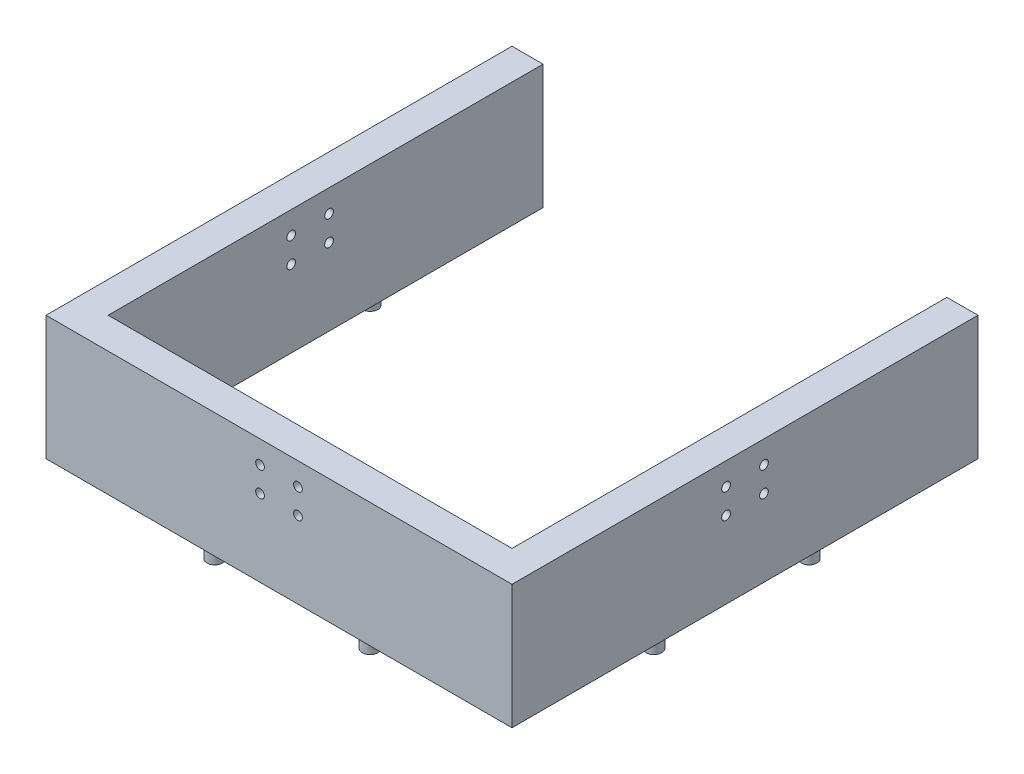
from build123d import *

# Parameters (mm, degrees)
SKETCH1_W           = 150
SKETCH1_H           = 150
BOSS_EXTRUDE1_DEPTH = 40
SKETCH2_W           = 130
SKETCH2_H           = 130
CUT_EXTRUDE1_DEPTH  = 54
SKETCH6_R           = 2.5
BOSS_EXTRUDE5_DEPTH = 5
SKETCH9_R           = 1.4
CUT_EXTRUDE4_DEPTH  = 10
CIRPATTERN1_COUNT   = 3
CIRPATTERN1_ANGLE   = 180
SKETCH10_W          = 130
SKETCH10_H          = 96.398295943
CUT_EXTRUDE6_DEPTH  = 116.217186218


with BuildPart() as part:
    # Sketch1 → Boss-Extrude1 (new body)
    with BuildSketch(Plane(origin=(0, 0, 0), x_dir=(1, 0, 0), z_dir=(0, 1, 0))):
        Rectangle(SKETCH1_W, SKETCH1_H)
    extrude(amount=-BOSS_EXTRUDE1_DEPTH)

    # Sketch2 → Cut-Extrude1 (cut)
    with BuildSketch(Plane(origin=(0, 0, 0), x_dir=(1, 0, 0), z_dir=(0, 1, 0))):
        Rectangle(SKETCH2_W, SKETCH2_H)
    extrude(amount=-CUT_EXTRUDE1_DEPTH, mode=Mode.SUBTRACT)

    # Sketch6 → Boss-Extrude5 (add)
    with BuildSketch(Plane.XZ.offset(40)):
        with Locations((-70.678187872, -25)):
            Circle(SKETCH6_R)
        with Locations((-70.678187872, 25)):
            Circle(SKETCH6_R)
        with Locations((25, 70.678187872)):
            Circle(SKETCH6_R)
        with Locations((-25, 70.678187872)):
            Circle(SKETCH6_R)
        with Locations((70.678187872, -25)):
            Circle(SKETCH6_R)
        with Locations((70.678187872, 25)):
            Circle(SKETCH6_R)
        with Locations((-25, -70.678187872)):
            Circle(SKETCH6_R)
        with Locations((25, -70.678187872)):
            Circle(SKETCH6_R)
    extrude(amount=BOSS_EXTRUDE5_DEPTH)

    # Sketch9 → Cut-Extrude4 (cut)
    with BuildSketch(Plane.ZY.offset(75)):
        with Locations((-6.1, -7.25)):
            Circle(SKETCH9_R)
        with Locations((6.1, -7.25)):
            Circle(SKETCH9_R)
        with Locations((6.1, -15.25)):
            Circle(SKETCH9_R)
        with Locations((-6.1, -15.25)):
            Circle(SKETCH9_R)
    cut_extrude4 = extrude(amount=-CUT_EXTRUDE4_DEPTH, mode=Mode.SUBTRACT)

    # CirPattern1: Cut-Extrude4 ×3 about axis
    cirpattern1_axis = Axis((0, 0, 0), (0, 1, 0))
    for i in range(1, CIRPATTERN1_COUNT):
        add(cut_extrude4.rotate(cirpattern1_axis, i * CIRPATTERN1_ANGLE / (CIRPATTERN1_COUNT - 1)), mode=Mode.SUBTRACT)

    # Sketch10 → Cut-Extrude6 (cut, through all)
    with BuildSketch(Plane(origin=(0, 0, 0), x_dir=(1, 0, 0), z_dir=(0, 1, 0))):
        with Locations((0, 113.199147972)):
            Rectangle(SKETCH10_W, SKETCH10_H)
    extrude(amount=-CUT_EXTRUDE6_DEPTH, mode=Mode.SUBTRACT)


solid = part.part
